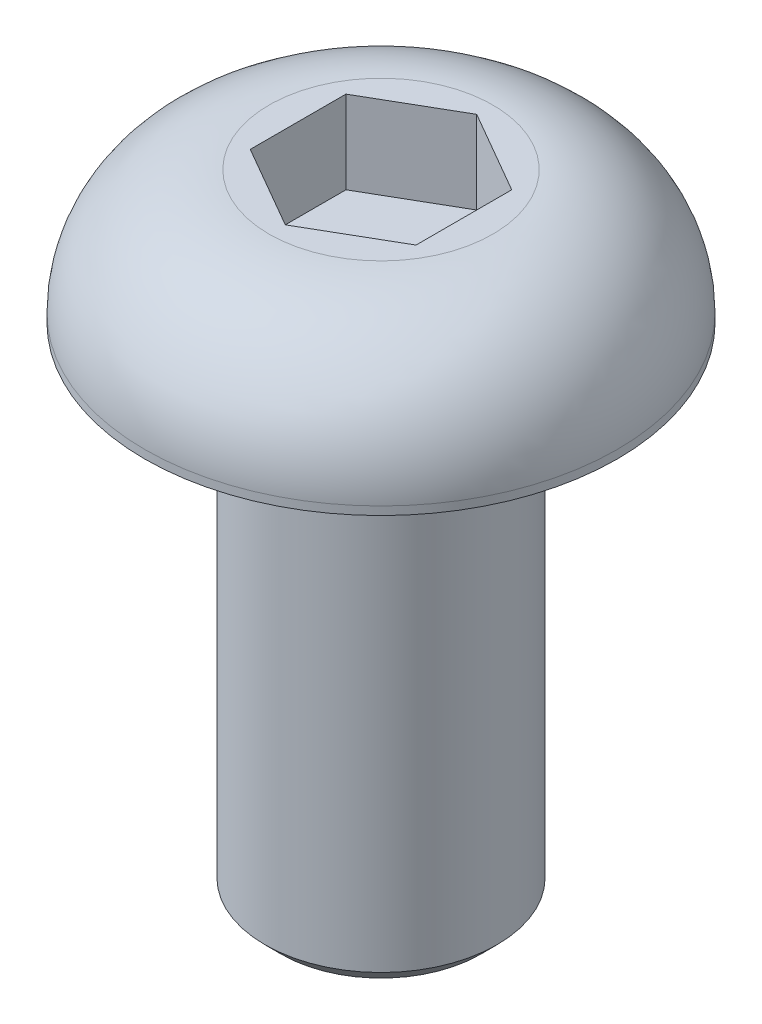
from build123d import *

# Parameters (mm, degrees)
SKETCH_1_R          = 2.85
EXTRUDE_1_DEPTH     = 1.6
CUT_EXTRUDE_1_DEPTH = 1
FILLET_1_R          = 1.5
SKETCH_3_R          = 1.4
EXTRUDE_2_DEPTH     = 6
CHAMFER_1_SIZE      = 0.2


with BuildPart() as part:
    # 草图1 → 凸台-拉伸1 (new body)
    with BuildSketch(Plane(origin=(0, 0, 0), x_dir=(1, 0, 0), z_dir=(0, 1, 0))):
        Circle(SKETCH_1_R)
    extrude(amount=EXTRUDE_1_DEPTH)

    # 草图2 → 切除-拉伸1 (cut)
    with BuildSketch(Plane(origin=(0, 1.6, 0), x_dir=(1, 0, 0), z_dir=(0, 1, 0))):
        Polygon((0, -1.154700538), (1, -0.577350269), (1, 0.577350269), (0, 1.154700538), (-1, 0.577350269), (-1, -0.577350269), align=None)
    extrude(amount=-CUT_EXTRUDE_1_DEPTH, mode=Mode.SUBTRACT)

    # 圆角1
    fillet_1_edges = [part.edges().sort_by_distance(p)[0] for p in [
        (-2.85, 1.6, 0),
    ]]
    fillet(fillet_1_edges, radius=FILLET_1_R)

    # 草图3 → 凸台-拉伸2 (add)
    with BuildSketch(Plane.XZ):
        Circle(SKETCH_3_R)
    extrude(amount=EXTRUDE_2_DEPTH)

    # 倒角1
    chamfer_1_edges = [part.edges().sort_by_distance(p)[0] for p in [
        (-1.4, -6, 0),
    ]]
    chamfer(chamfer_1_edges, length=CHAMFER_1_SIZE)


solid = part.part
